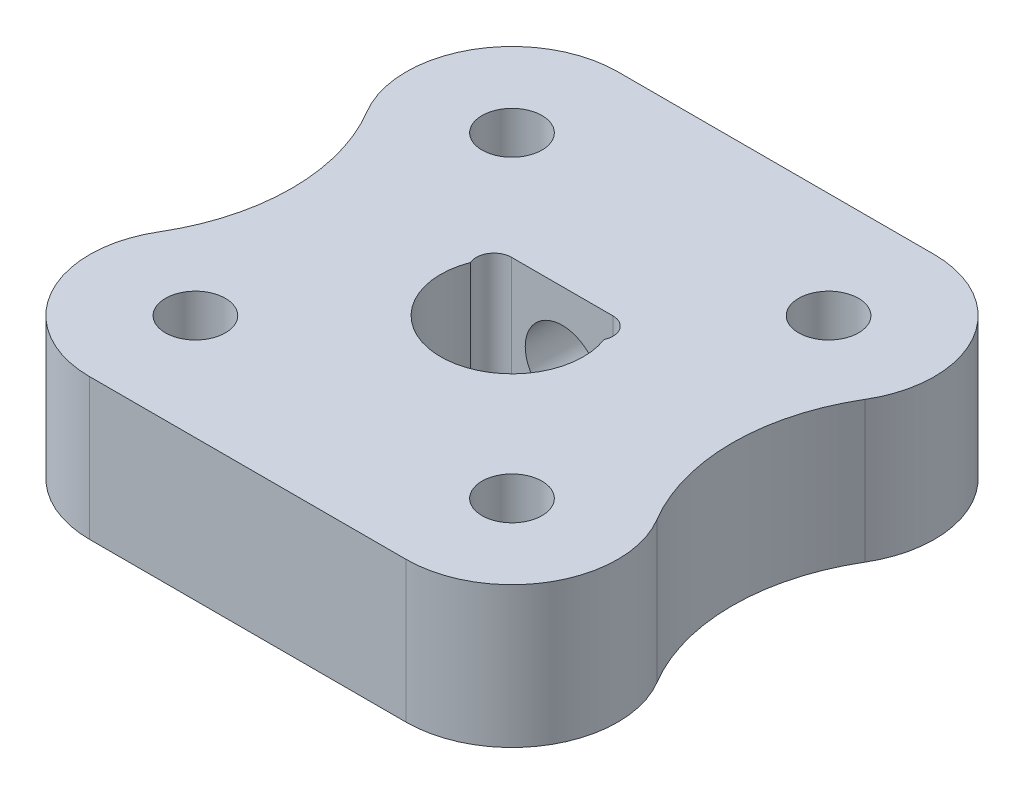
from build123d import *

# Parameters (mm, degrees)
SKETCH1_R                 = 0.85
BASE_SHAPE_DEPTH          = 4
M2_5_GRUB_SCREW_CUT_REACH = 16.98
SKETCH3_R                 = 1.05


with BuildPart() as part:
    # Sketch1 → Base shape (new body)
    with BuildSketch(Plane(origin=(0, 0, 0), x_dir=(1, 0, 0), z_dir=(0, 1, 0))):
        with BuildLine():
            Line((4.490128061, 7.490128061), (-4.490128061, 7.490128061))
            ThreePointArc((-4.490128061, 7.490128061), (-7.099636787, 5.970149752), (-7.064881074, 2.950437533))
            ThreePointArc((-7.064881074, 2.950437533), (-6.25, 0), (-7.064881074, -2.950437533))
            ThreePointArc((-7.064881074, -2.950437533), (-7.099636787, -5.970149752), (-4.490128061, -7.490128061))
            Line((-4.490128061, -7.490128061), (4.490128061, -7.490128061))
            ThreePointArc((4.490128061, -7.490128061), (7.099636787, -5.970149752), (7.064881074, -2.950437533))
            ThreePointArc((7.064881074, -2.950437533), (6.25, 0), (7.064881074, 2.950437533))
            ThreePointArc((7.064881074, 2.950437533), (7.099636787, 5.970149752), (4.490128061, 7.490128061))
        make_face()
        with BuildLine():
            Line((-1.438749457, 1.425), (1.438749457, 1.425))
            ThreePointArc((1.438749457, 1.425), (1.859326776, 1.195397336), (1.893641402, 0.717458876))
            ThreePointArc((1.893641402, 0.717458876), (0, -2.025), (-1.893641402, 0.717458876))
            ThreePointArc((-1.893641402, 0.717458876), (-1.859326776, 1.195397336), (-1.438749457, 1.425))
        make_face(mode=Mode.SUBTRACT)
        with Locations((-4.490128061, 4.490128061)):
            Circle(SKETCH1_R, mode=Mode.SUBTRACT)
        with Locations((4.490128061, 4.490128061)):
            Circle(SKETCH1_R, mode=Mode.SUBTRACT)
        with Locations((-4.490128061, -4.490128061)):
            Circle(SKETCH1_R, mode=Mode.SUBTRACT)
        with Locations((4.490128061, -4.490128061)):
            Circle(SKETCH1_R, mode=Mode.SUBTRACT)
    extrude(amount=BASE_SHAPE_DEPTH)

    # Sketch3 → M2.5 Grub screw cut (cut, up to next)
    with BuildSketch(Plane.XY.offset(-7.490128061), mode=Mode.PRIVATE) as m2_5_grub_screw_cut_sk1:
        with Locations((0, 2)):
            Circle(SKETCH3_R)
    m2_5_grub_screw_cut_tool1 = extrude(m2_5_grub_screw_cut_sk1.sketch, amount=M2_5_GRUB_SCREW_CUT_REACH, mode=Mode.PRIVATE) & part.part
    add(m2_5_grub_screw_cut_tool1.solids().sort_by_distance((0, 2, -7.490128))[0], mode=Mode.SUBTRACT)


solid = part.part
